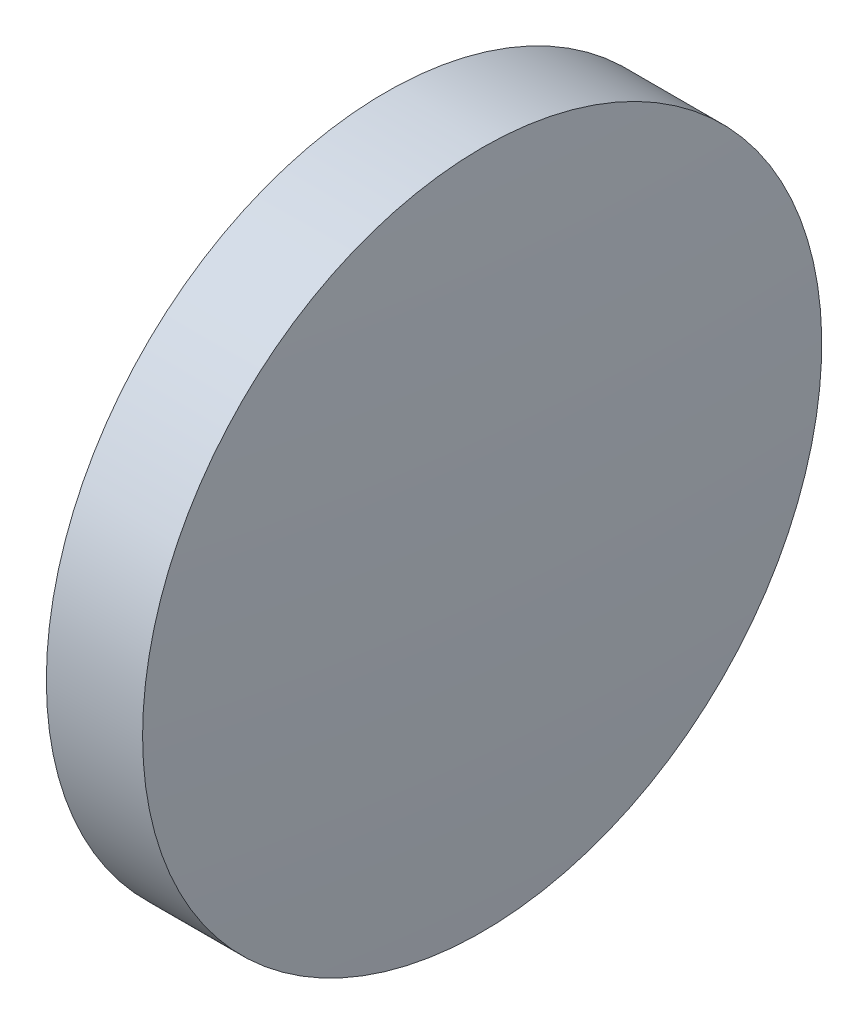
from build123d import *


with BuildPart() as part:
    # 草图1 → 旋转1 (revolve)
    with BuildSketch(Plane.XY):
        with BuildLine():
            Line((348.068523868, 151.839578728), (348.068523868, 164.539578728))
            Line((348.068523868, 164.539578728), (351.668523868, 164.539578728))
            ThreePointArc((351.668523868, 164.539578728), (351.96849908, 158.192727554), (352.068523868, 151.839578728))
            Line((352.068523868, 151.839578728), (348.068523868, 151.839578728))
        make_face()
    revolve(axis=Axis((342.330305832, 151.839578728, 0), (1, 0, 0)))


solid = part.part
